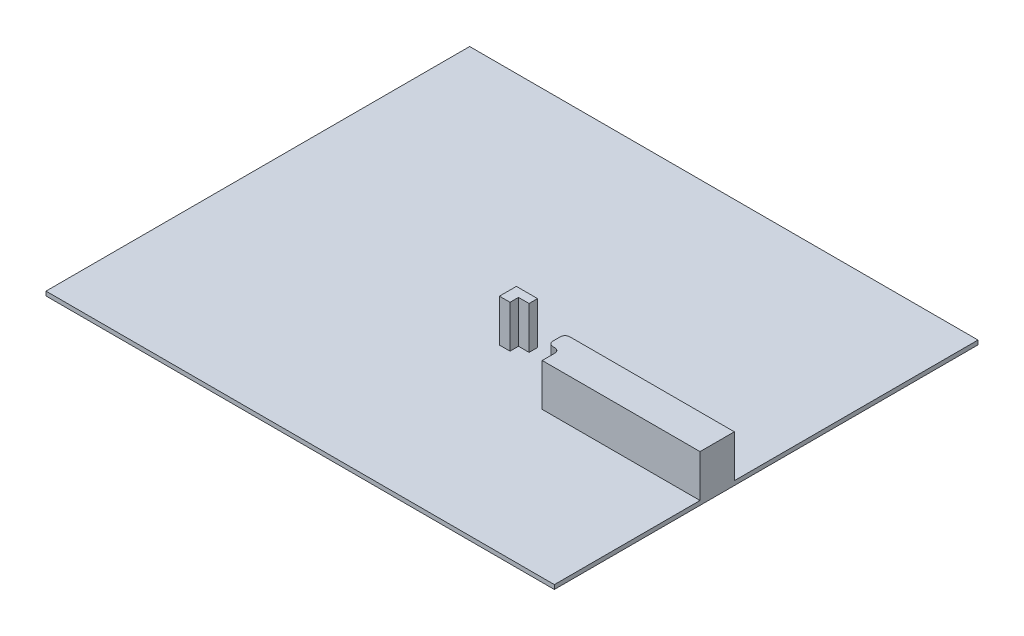
from build123d import *

# Parameters (mm, degrees)
SKETCH2_W           = 1200
SKETCH2_H           = 1000
BOSS_EXTRUDE1_DEPTH = 10
BOSS_EXTRUDE2_DEPTH = 100
BOSS_EXTRUDE3_DEPTH = 100


with BuildPart() as part:
    # Sketch2 → Boss-Extrude1 (new body)
    with BuildSketch(Plane(origin=(0, 0, 0), x_dir=(1, 0, 0), z_dir=(0, 1, 0))):
        Rectangle(SKETCH2_W, SKETCH2_H)
    extrude(amount=BOSS_EXTRUDE1_DEPTH)

    # Sketch4 → Boss-Extrude2 (add)
    with BuildSketch(Plane(origin=(0, 10, 0), x_dir=(1, 0, 0), z_dir=(0, 1, 0))):
        with BuildLine():
            Line((211.500312891, -115.173130931), (216.500312891, -115.173130931))
            ThreePointArc((216.500312891, -115.173130931), (224.278487484, -118.394956338), (227.500312891, -126.173130931))
            Line((227.500312891, -126.173130931), (227.500312891, -156.173130931))
            Line((227.500312891, -156.173130931), (600, -156.173130931))
            Line((600, -156.173130931), (600, -95.173130931))
            Line((600, -95.173130931), (600, -75.173130931))
            Line((600, -75.173130931), (211.500312891, -75.173130931))
            ThreePointArc((211.500312891, -75.173130931), (203.722138298, -78.394956338), (200.500312891, -86.173130931))
            Line((200.500312891, -86.173130931), (200.500312891, -104.173130931))
            ThreePointArc((200.500312891, -104.173130931), (203.722138298, -111.951305524), (211.500312891, -115.173130931))
        make_face()
    extrude(amount=BOSS_EXTRUDE2_DEPTH)

    # Sketch5 → Boss-Extrude3 (add)
    with BuildSketch(Plane(origin=(0, 10, 0), x_dir=(1, 0, 0), z_dir=(0, 1, 0))):
        Polygon((95.500312891, -55.173130931), (95.500312891, -35.173130931), (45.500312891, -35.173130931), (45.500312891, -75.173130931), (70.500312891, -75.173130931), (70.500312891, -55.173130931), align=None)
    extrude(amount=BOSS_EXTRUDE3_DEPTH)


solid = part.part
